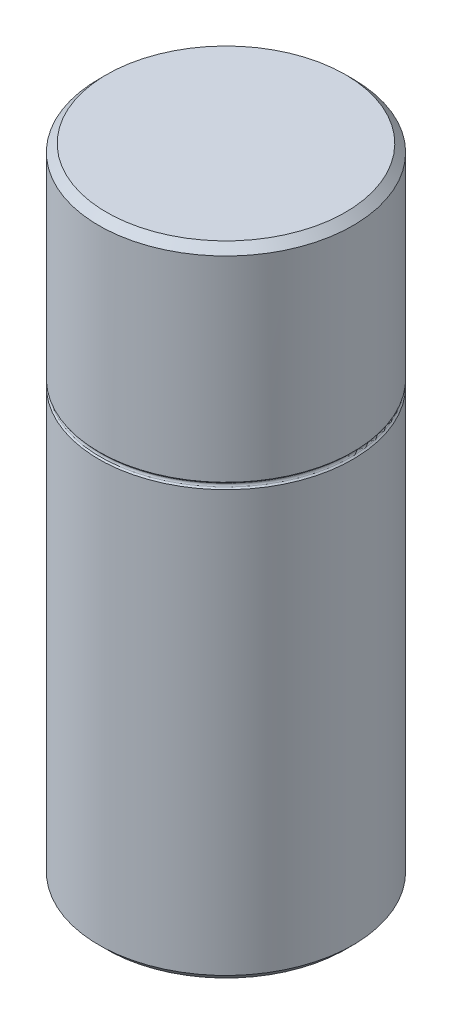
from build123d import *


with BuildPart() as part:
    # Sketch1 → Revolve1 (revolve)
    with BuildSketch(Plane.XY, mode=Mode.PRIVATE) as revolve1_sk:
        Polygon((12.6365, 0.762), (12.6365, 62.738), (11.8745, 63.5), (0, 63.5), (0, 4.826), (6.1341, 4.826), (6.3881, 4.572), (6.3881, 0), (11.8745, 0), align=None)
    revolve(revolve1_sk.sketch.rotate(Axis((0, 0, 0), (0, 1, 0)), 90), axis=Axis((0, 0, 0), (0, 1, 0)))  # turned: the seam where the file's is

    # Sketch2 → Cut-Revolve1 (revolve, cut)
    with BuildSketch(Plane.XY, mode=Mode.PRIVATE) as cut_revolve1_sk:
        with BuildLine():
            Line((12.7, 43.307), (12.7, 42.545))
            Line((12.7, 42.545), (12.498605122, 42.746394878))
            ThreePointArc((12.498605122, 42.746394878), (12.424210245, 42.926), (12.498605122, 43.105605122))
            Line((12.498605122, 43.105605122), (12.7, 43.307))
        make_face()
    revolve(cut_revolve1_sk.sketch.rotate(Axis((0, 0, 0), (0, 1, 0)), 90), axis=Axis((0, 0, 0), (0, 1, 0)), mode=Mode.SUBTRACT)  # turned: the seam where the file's is


solid = part.part
